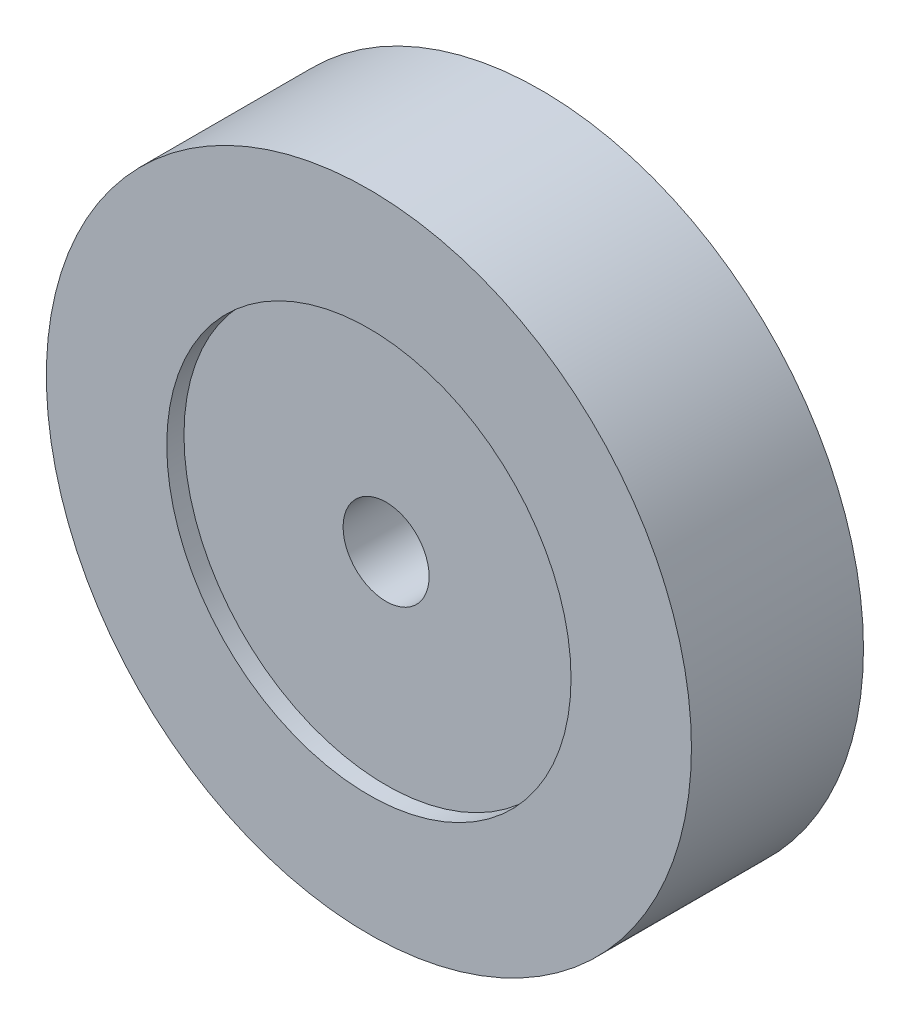
from build123d import *

# Parameters (mm, degrees)
SKETCH1_R           = 4.7625
SKETCH1_R_2         = 0.635
BOSS_EXTRUDE1_DEPTH = 2.54
SKETCH2_R           = 2.9845
CUT_EXTRUDE1_DEPTH  = 0.254
CUT_EXTRUDE2_START  = -0.254
SKETCH3_R           = 2.9845
CUT_EXTRUDE2_DEPTH  = 0.254


with BuildPart() as part:
    # Sketch1 → Boss-Extrude1 (new body)
    with BuildSketch(Plane.XY):
        Circle(SKETCH1_R)
        Circle(SKETCH1_R_2, mode=Mode.SUBTRACT)
    extrude(amount=BOSS_EXTRUDE1_DEPTH)

    # Sketch2 → Cut-Extrude1 (cut)
    with BuildSketch(Plane.XY.offset(2.54)):
        Circle(SKETCH2_R)
    extrude(amount=-CUT_EXTRUDE1_DEPTH, mode=Mode.SUBTRACT)

    # Sketch3 → Cut-Extrude2 (cut)
    with BuildSketch(Plane(origin=(0, 0, 0), x_dir=(-1, 0, 0), z_dir=(0, 0, -1)).offset(CUT_EXTRUDE2_START)):
        with Locations(Location((0, 0, 0), (0, 0, 180))):
            Circle(SKETCH3_R)
    extrude(amount=CUT_EXTRUDE2_DEPTH, mode=Mode.SUBTRACT)


solid = part.part
